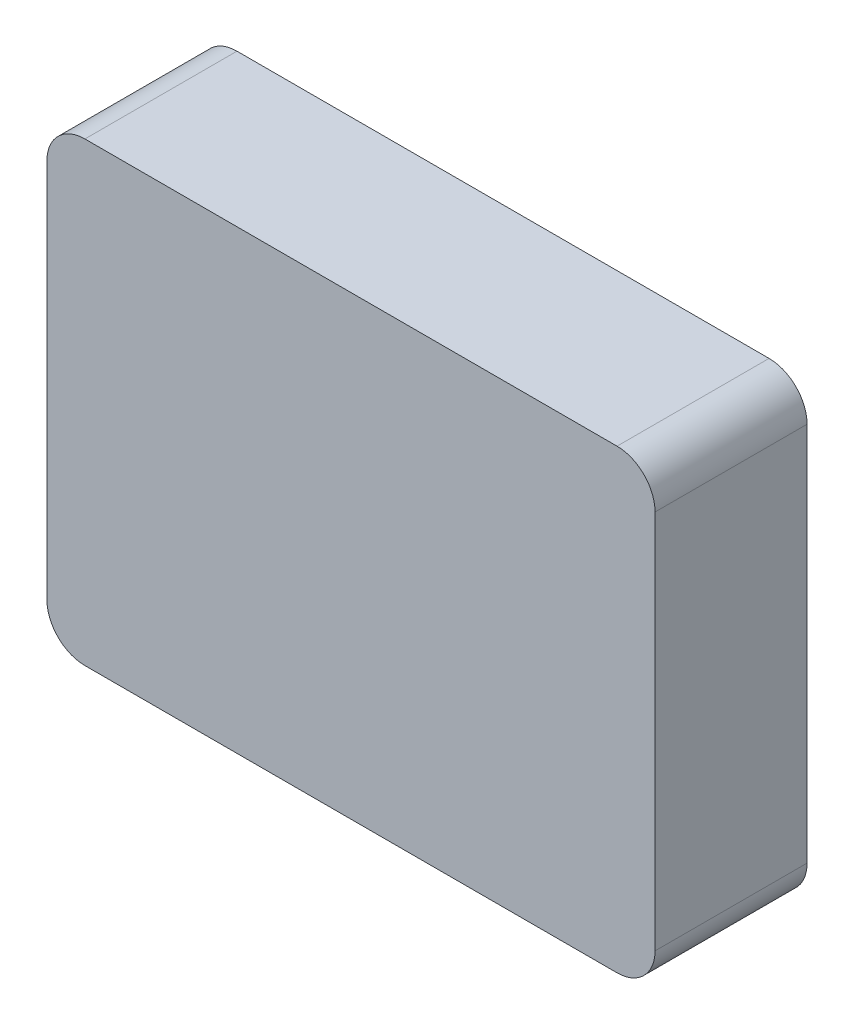
from build123d import *

# Parameters (mm, degrees)
ESQUISSE1_W        = 32
ESQUISSE1_H        = 24
BOSS_EXTRU_1_DEPTH = 8
CONG_1_R           = 2


with BuildPart() as part:
    # Esquisse1 → Boss.-Extru.1 (new body)
    with BuildSketch(Plane.XY):
        with Locations((16, -12)):
            Rectangle(ESQUISSE1_W, ESQUISSE1_H)
    extrude(amount=BOSS_EXTRU_1_DEPTH)

    # Congé1
    cong_1_edges = [part.edges().sort_by_distance(p)[0] for p in [
        (0, 0, 4),
        (32, 0, 4),
        (32, -24, 4),
        (0, -24, 4),
    ]]
    fillet(cong_1_edges, radius=CONG_1_R)


solid = part.part
